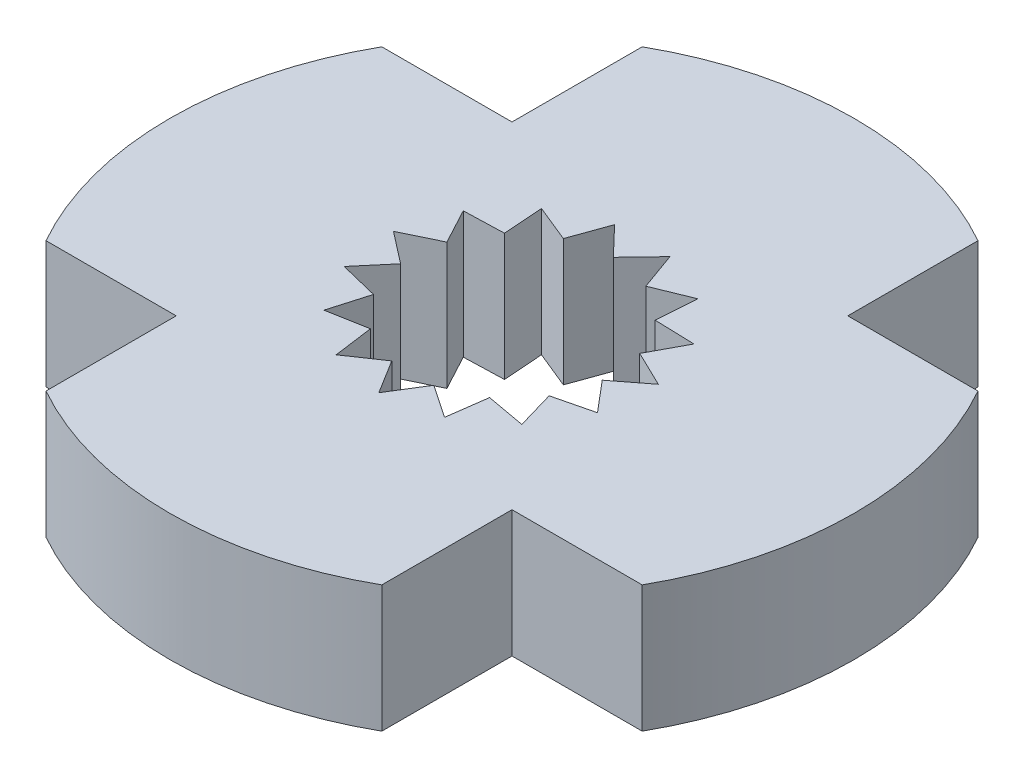
from build123d import *

# Parameters (mm, degrees)
EXTRUDE_1_DEPTH     = 2
CUT_EXTRUDE_2_DEPTH = 2.2


with BuildPart() as part:
    # ｽｹｯﾁ1 → ﾎﾞｽ - 押し出し1 (new body)
    with BuildSketch(Plane(origin=(0, 0, 0), x_dir=(1, 0, 0), z_dir=(0, 1, 0))):
        with BuildLine():
            Line((2.65, 4.705050478), (2.65, 2.65))
            Line((2.65, 2.65), (4.705050478, 2.65))
            ThreePointArc((4.705050478, 2.65), (5.4, 0), (4.705050478, -2.65))
            Line((4.705050478, -2.65), (2.65, -2.65))
            Line((2.65, -2.65), (2.65, -4.705050478))
            ThreePointArc((2.65, -4.705050478), (0, -5.4), (-2.65, -4.705050478))
            Line((-2.65, -4.705050478), (-2.65, -2.65))
            Line((-2.65, -2.65), (-4.705050478, -2.65))
            ThreePointArc((-4.705050478, -2.65), (-5.4, 0), (-4.705050478, 2.65))
            Line((-4.705050478, 2.65), (-2.65, 2.65))
            Line((-2.65, 2.65), (-2.65, 4.705050478))
            ThreePointArc((-2.65, 4.705050478), (0, 5.4), (2.65, 4.705050478))
        make_face()
    extrude(amount=EXTRUDE_1_DEPTH)

    # ｽｹｯﾁ4 → ｶｯﾄ - 押し出し2 (cut)
    with BuildSketch(Plane(origin=(0, 2, 0), x_dir=(1, 0, 0), z_dir=(0, 1, 0))):
        Polygon((0, 1.6), (0.437016815, 2.056002469), (0.650778629, 1.461672732), (1.235486269, 1.700500964), (1.189031721, 1.07060897), (1.820328922, 1.050967393), (1.521690426, 0.494427191), (2.090420168, 0.219712013), (1.591235033, -0.167245541), (1.999058776, -0.64953357), (1.385640646, -0.8), (1.56204196, -1.406468898), (0.940456404, -1.294427191), (0.854933899, -1.920212977), (0.332658705, -1.565036161), (0, -2.101934787), (-0.332658705, -1.565036161), (-0.854933899, -1.920212977), (-0.940456404, -1.294427191), (-1.56204196, -1.406468898), (-1.385640646, -0.8), (-1.999058776, -0.64953357), (-1.591235033, -0.167245541), (-2.090420168, 0.219712013), (-1.521690426, 0.494427191), (-1.820328922, 1.050967393), (-1.189031721, 1.07060897), (-1.235486269, 1.700500964), (-0.650778629, 1.461672732), (-0.437016815, 2.056002469), align=None)
    extrude(amount=-CUT_EXTRUDE_2_DEPTH, mode=Mode.SUBTRACT)


solid = part.part
